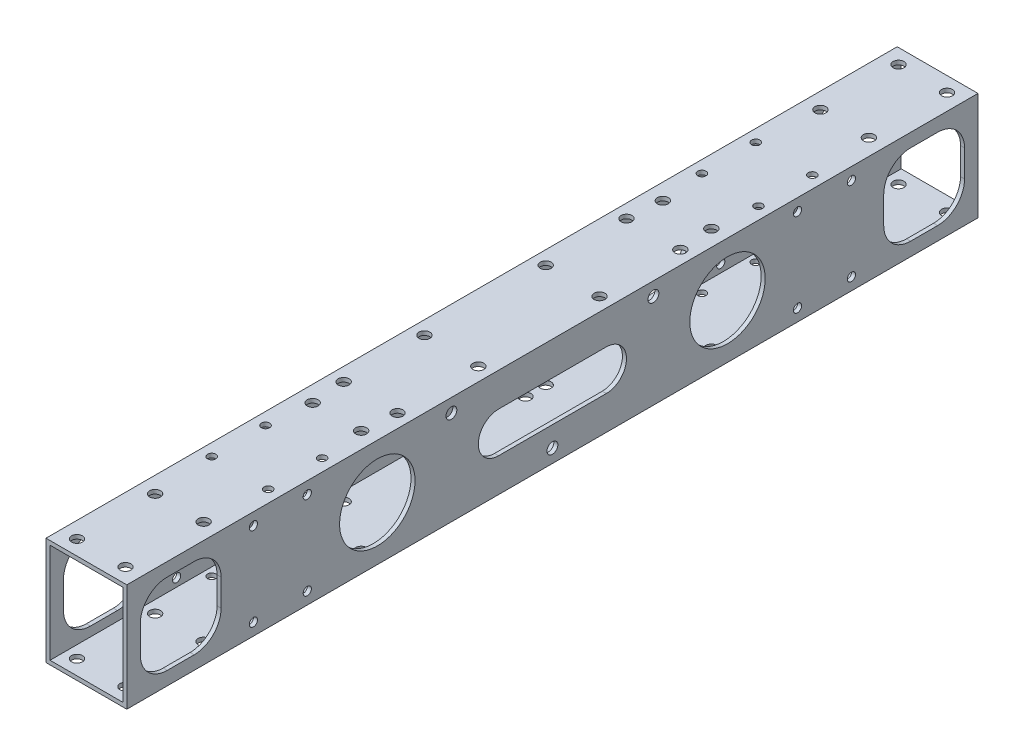
from build123d import *

# Parameters (mm, degrees)
SKETCH_1_W               = 30
SKETCH_1_H               = 40
SKETCH_1_W_2             = 27
SKETCH_1_H_2             = 37
EXTRUDE_1_DEPTH          = 158
SKETCH_2_R               = 14
SKETCH_2_W               = 30
SKETCH_2_H               = 30
CUT_EXTRUDE_1_DEPTH      = 50
FILLET_1_R               = 10
SKETCH_4_R               = 2.025
CUT_EXTRUDE_2_DEPTH      = 40
SKETCH_5_R               = 2.025
CUT_EXTRUDE_3_DEPTH      = 50
SKETCH_7_R               = 2.025
CUT_EXTRUDE_4_DEPTH      = 47
SKETCH_8_R               = 2.025
CUT_EXTRUDE_5_DEPTH      = 67
SKETCH_9_R               = 2.025
CUT_EXTRUDE_6_DEPTH      = 27
SKETCH_10_R              = 1.525
CUT_EXTRUDE_7_DEPTH      = 10
SKETCH_11_R              = 1.525
CUT_EXTRUDE_8_DEPTH      = 10
MIRROR_3_COPY_1_SKETCH_R = 1.525
MIRROR_3_COPY_1_DEPTH    = 10
MIRROR_3_COPY_2_SKETCH_R = 1.525
MIRROR_3_COPY_2_DEPTH    = 10
MIRROR_4_COPY_1_SKETCH_R = 1.525
MIRROR_4_COPY_1_DEPTH    = 10
MIRROR_4_COPY_2_SKETCH_R = 1.525
MIRROR_4_COPY_2_DEPTH    = 10
MIRROR_4_COPY_3_SKETCH_R = 1.525
MIRROR_4_COPY_3_DEPTH    = 10
MIRROR_4_COPY_4_SKETCH_R = 1.525
MIRROR_4_COPY_4_DEPTH    = 10
MIRROR_4_COPY_5_SKETCH_R = 1.525
MIRROR_4_COPY_5_DEPTH    = 10
MIRROR_4_COPY_6_SKETCH_R = 1.525
MIRROR_4_COPY_6_DEPTH    = 10
SKETCH_12_R              = 2.025
CUT_EXTRUDE_9_DEPTH      = 60


with BuildPart() as part:
    # 草图1 → 凸台-拉伸1 (new body, symmetric)
    with BuildSketch(Plane.XY):
        Rectangle(SKETCH_1_W, SKETCH_1_H)
        Rectangle(SKETCH_1_W_2, SKETCH_1_H_2, mode=Mode.SUBTRACT)
    extrude(amount=EXTRUDE_1_DEPTH, both=True)

    # 草图2 → 切除-拉伸1 (cut)
    with BuildSketch(Plane(origin=(15, 0, 0), x_dir=(0, 0, -1), z_dir=(1, 0, 0))):
        with Locations((-65, 0)):
            Circle(SKETCH_2_R)
        with Locations((65, 0)):
            Circle(SKETCH_2_R)
        with Locations((-138, 0)):
            Rectangle(SKETCH_2_W, SKETCH_2_H)
        with Locations((138, 0)):
            Rectangle(SKETCH_2_W, SKETCH_2_H)
        with BuildLine():
            Line((-20, 7.5), (20, 7.5))
            ThreePointArc((20, 7.5), (27.5, 0), (20, -7.5))
            Line((20, -7.5), (-20, -7.5))
            ThreePointArc((-20, -7.5), (-27.5, 0), (-20, 7.5))
        make_face()
    extrude(amount=-CUT_EXTRUDE_1_DEPTH, mode=Mode.SUBTRACT)

    # 圆角1
    fillet_1_edges = [part.edges().sort_by_distance(p)[0] for p in [
        (-14.25, 15, 123),
        (14.25, 15, 123),
        (-14.25, -15, 123),
        (14.25, -15, 123),
        (-14.25, -15, 153),
        (14.25, -15, 153),
        (-14.25, 15, 153),
        (14.25, 15, 153),
        (-14.25, 15, -153),
        (14.25, 15, -153),
        (-14.25, -15, -153),
        (14.25, -15, -153),
        (-14.25, -15, -123),
        (14.25, -15, -123),
        (-14.25, 15, -123),
        (14.25, 15, -123),
    ]]
    fillet(fillet_1_edges, radius=FILLET_1_R)

    # 草图4 → 切除-拉伸2 (cut)
    with BuildSketch(Plane(origin=(0, 20, 0), x_dir=(1, 0, 0), z_dir=(0, 1, 0))):
        with Locations((-9, 152.5)):
            Circle(SKETCH_4_R)
        with Locations((9, 152.5)):
            Circle(SKETCH_4_R)
        with Locations((-9, 123.5)):
            Circle(SKETCH_4_R)
        with Locations((9, 123.5)):
            Circle(SKETCH_4_R)
        with Locations((-9, 65)):
            Circle(SKETCH_4_R)
        with Locations((9, 65)):
            Circle(SKETCH_4_R)
    cut_extrude_2 = extrude(amount=-CUT_EXTRUDE_2_DEPTH, mode=Mode.SUBTRACT)

    # 镜向1: 切除-拉伸2 across plane
    add(cut_extrude_2.mirror(Plane.XY), mode=Mode.SUBTRACT)

    # 草图5 → 切除-拉伸3 (cut)
    with BuildSketch(Plane(origin=(0, 20, 0), x_dir=(1, 0, 0), z_dir=(0, 1, 0))):
        with Locations((10, 52.5)):
            Circle(SKETCH_5_R)
        with Locations((10, -52.5)):
            Circle(SKETCH_5_R)
        with Locations((-10, -52.5)):
            Circle(SKETCH_5_R)
        with Locations((-10, 52.5)):
            Circle(SKETCH_5_R)
    extrude(amount=-CUT_EXTRUDE_3_DEPTH, mode=Mode.SUBTRACT)

    # 草图7 → 切除-拉伸4 (cut)
    with BuildSketch(Plane(origin=(15, 0, 0), x_dir=(0, 0, -1), z_dir=(1, 0, 0))):
        with Locations((-37.5, 15)):
            Circle(SKETCH_7_R)
        with Locations((37.5, 15)):
            Circle(SKETCH_7_R)
    extrude(amount=-CUT_EXTRUDE_4_DEPTH, mode=Mode.SUBTRACT)

    # 草图8 → 切除-拉伸5 (cut)
    with BuildSketch(Plane(origin=(15, 0, 0), x_dir=(0, 0, -1), z_dir=(1, 0, 0))):
        with Locations((0, -15)):
            Circle(SKETCH_8_R)
    extrude(amount=-CUT_EXTRUDE_5_DEPTH, mode=Mode.SUBTRACT)

    # 草图9 → 切除-拉伸6 (cut)
    with BuildSketch(Plane.XZ.offset(20)):
        with Locations((10, 15)):
            Circle(SKETCH_9_R)
        with Locations((10, -15)):
            Circle(SKETCH_9_R)
        with Locations((-10, -15)):
            Circle(SKETCH_9_R)
        with Locations((-10, 15)):
            Circle(SKETCH_9_R)
    extrude(amount=-CUT_EXTRUDE_6_DEPTH, mode=Mode.SUBTRACT)

    # 草图10 → 切除-拉伸7 (cut)
    with BuildSketch(Plane(origin=(15, 0, 0), x_dir=(0, 0, -1), z_dir=(1, 0, 0))):
        with Locations((91, 15.5)):
            Circle(SKETCH_10_R)
        with Locations((111, 15.5)):
            Circle(SKETCH_10_R)
    cut_extrude_7 = extrude(amount=-CUT_EXTRUDE_7_DEPTH, mode=Mode.SUBTRACT)

    # 草图11 → 切除-拉伸8 (cut)
    with BuildSketch(Plane(origin=(0, 20, 0), x_dir=(1, 0, 0), z_dir=(0, 1, 0))):
        with Locations((10.5, 101)):
            Circle(SKETCH_11_R)
        with Locations((10.5, 81)):
            Circle(SKETCH_11_R)
    cut_extrude_8 = extrude(amount=-CUT_EXTRUDE_8_DEPTH, mode=Mode.SUBTRACT)

    # 镜向2: 切除-拉伸7, 切除-拉伸8 across plane
    add(cut_extrude_7.mirror(Plane.XY), mode=Mode.SUBTRACT)
    add(cut_extrude_8.mirror(Plane.XY), mode=Mode.SUBTRACT)

    # 镜向3: 切除-拉伸7, 切除-拉伸8 across plane
    add(cut_extrude_7.mirror(Plane.ZX), mode=Mode.SUBTRACT)
    add(cut_extrude_8.mirror(Plane.ZX), mode=Mode.SUBTRACT)

    # 镜向3 copy 1 sketch → 镜向3 copy 1 (cut)
    with BuildSketch(Plane(origin=(15, 0, 0), x_dir=(0, 0, 1), z_dir=(1, 0, 0))):
        with Locations((91, 15.5)):
            Circle(MIRROR_3_COPY_1_SKETCH_R)
        with Locations((111, 15.5)):
            Circle(MIRROR_3_COPY_1_SKETCH_R)
    extrude(amount=-MIRROR_3_COPY_1_DEPTH, mode=Mode.SUBTRACT)

    # 镜向3 copy 2 sketch → 镜向3 copy 2 (cut)
    with BuildSketch(Plane.XZ.offset(20)):
        with Locations((10.5, 101)):
            Circle(MIRROR_3_COPY_2_SKETCH_R)
        with Locations((10.5, 81)):
            Circle(MIRROR_3_COPY_2_SKETCH_R)
    extrude(amount=-MIRROR_3_COPY_2_DEPTH, mode=Mode.SUBTRACT)

    # 镜向4: 切除-拉伸7, 切除-拉伸8 across plane
    add(cut_extrude_7.mirror(Plane(origin=(0, 0, 0), x_dir=(0, 0, 1), z_dir=(1, 0, 0))), mode=Mode.SUBTRACT)
    add(cut_extrude_8.mirror(Plane(origin=(0, 0, 0), x_dir=(0, 0, 1), z_dir=(1, 0, 0))), mode=Mode.SUBTRACT)

    # 镜向4 copy 1 sketch → 镜向4 copy 1 (cut)
    with BuildSketch(Plane(origin=(-15, 0, 0), x_dir=(0, 0, -1), z_dir=(-1, 0, 0))):
        with Locations((91, 15.5)):
            Circle(MIRROR_4_COPY_1_SKETCH_R)
        with Locations((111, 15.5)):
            Circle(MIRROR_4_COPY_1_SKETCH_R)
    extrude(amount=-MIRROR_4_COPY_1_DEPTH, mode=Mode.SUBTRACT)

    # 镜向4 copy 2 sketch → 镜向4 copy 2 (cut)
    with BuildSketch(Plane(origin=(0, -20, 0), x_dir=(-1, 0, 0), z_dir=(0, -1, 0))):
        with Locations((10.5, 101)):
            Circle(MIRROR_4_COPY_2_SKETCH_R)
        with Locations((10.5, 81)):
            Circle(MIRROR_4_COPY_2_SKETCH_R)
    extrude(amount=-MIRROR_4_COPY_2_DEPTH, mode=Mode.SUBTRACT)

    # 镜向4 copy 3 sketch → 镜向4 copy 3 (cut)
    with BuildSketch(Plane.ZY.offset(15)):
        with Locations((91, -15.5)):
            Circle(MIRROR_4_COPY_3_SKETCH_R)
        with Locations((111, -15.5)):
            Circle(MIRROR_4_COPY_3_SKETCH_R)
    extrude(amount=-MIRROR_4_COPY_3_DEPTH, mode=Mode.SUBTRACT)

    # 镜向4 copy 4 sketch → 镜向4 copy 4 (cut)
    with BuildSketch(Plane(origin=(0, -20, 0), x_dir=(-1, 0, 0), z_dir=(0, -1, 0))):
        with Locations((10.5, -101)):
            Circle(MIRROR_4_COPY_4_SKETCH_R)
        with Locations((10.5, -81)):
            Circle(MIRROR_4_COPY_4_SKETCH_R)
    extrude(amount=-MIRROR_4_COPY_4_DEPTH, mode=Mode.SUBTRACT)

    # 镜向4 copy 5 sketch → 镜向4 copy 5 (cut)
    with BuildSketch(Plane.ZY.offset(15)):
        with Locations((91, 15.5)):
            Circle(MIRROR_4_COPY_5_SKETCH_R)
        with Locations((111, 15.5)):
            Circle(MIRROR_4_COPY_5_SKETCH_R)
    extrude(amount=-MIRROR_4_COPY_5_DEPTH, mode=Mode.SUBTRACT)

    # 镜向4 copy 6 sketch → 镜向4 copy 6 (cut)
    with BuildSketch(Plane(origin=(0, 20, 0), x_dir=(-1, 0, 0), z_dir=(0, 1, 0))):
        with Locations((10.5, 101)):
            Circle(MIRROR_4_COPY_6_SKETCH_R)
        with Locations((10.5, 81)):
            Circle(MIRROR_4_COPY_6_SKETCH_R)
    extrude(amount=-MIRROR_4_COPY_6_DEPTH, mode=Mode.SUBTRACT)

    # 草图12 → 切除-拉伸9 (cut)
    with BuildSketch(Plane(origin=(0, 20, 0), x_dir=(1, 0, 0), z_dir=(0, 1, 0))):
        with Locations((-10, 22.5)):
            Circle(SKETCH_12_R)
        with Locations((10, 22.5)):
            Circle(SKETCH_12_R)
        with Locations((-10, -22.5)):
            Circle(SKETCH_12_R)
        with Locations((10, -22.5)):
            Circle(SKETCH_12_R)
    extrude(amount=-CUT_EXTRUDE_9_DEPTH, mode=Mode.SUBTRACT)


solid = part.part
